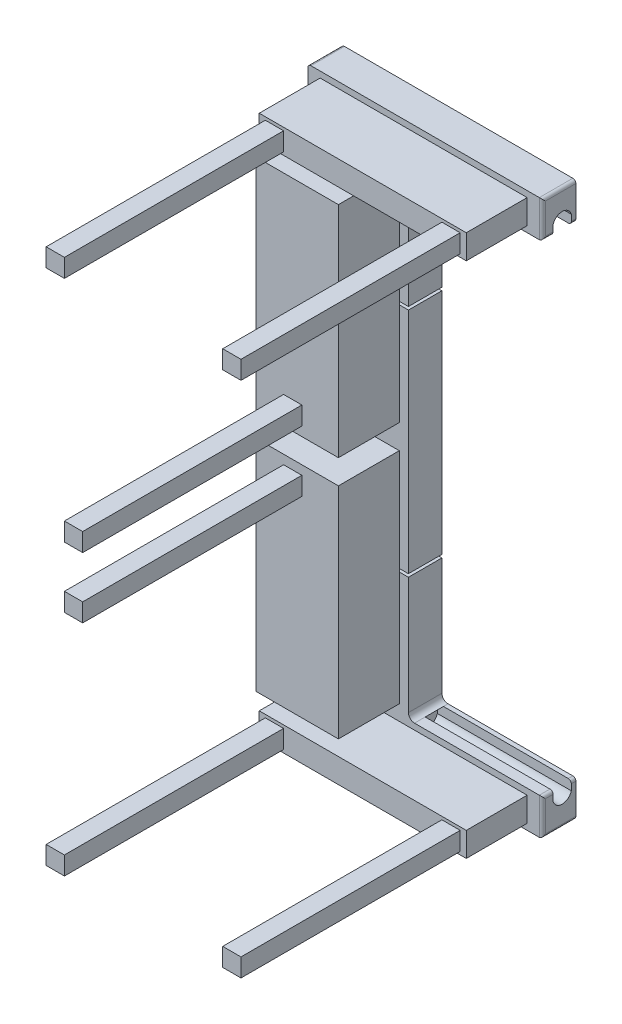
from build123d import *

# Parameters (mm, degrees)
BOSS_EXTRUDE1_DEPTH = 241.3
FILLET1_R           = 25.4
FILLET2_R           = 12.7
CUT_EXTRUDE1_DEPTH  = 558.8
SKETCH3_W           = 1114.093901139
SKETCH3_H           = 2455.440787086
CUT_EXTRUDE5_DEPTH  = 101.6
SKETCH4_W           = 139.7
SKETCH4_H           = 12.7
CUT_EXTRUDE6_DEPTH  = 401.32
SKETCH9_W           = 863.6
SKETCH9_H           = 101.6
SKETCH9_W_2         = 342.9
SKETCH9_H_2         = 914.4
BOSS_EXTRUDE5_DEPTH = 254
SKETCH10_W          = 76.2
SKETCH10_H          = 76.2
BOSS_EXTRUDE6_DEPTH = 914.4


with BuildPart() as part:
    # Sketch1 → Boss-Extrude1 (new body)
    with BuildSketch(Plane.XY):
        Polygon((977.9, -152.4), (419.1, -152.4), (419.1, -2159), (977.9, -2159), (977.9, -2311.4), (0, -2311.4), (0, 0), (977.9, 0), align=None)
    extrude(amount=BOSS_EXTRUDE1_DEPTH)

    # Fillet1
    fillet1_edges = [part.edges().sort_by_distance(p)[0] for p in [
        (419.1, -152.4, 120.65),
        (419.1, -2159, 120.65),
    ]]
    fillet(fillet1_edges, radius=FILLET1_R)

    # Fillet2
    fillet2_edges = [part.edges().sort_by_distance(p)[0] for p in [
        (977.9, -2235.2, 241.3),
        (0, 0, 120.65),
        (977.9, 0, 120.65),
        (977.9, -152.4, 120.65),
        (977.9, -2159, 120.65),
        (977.9, -2311.4, 120.65),
        (0, -2311.4, 120.65),
        (977.9, -76.2, 241.3),
        (977.9, -76.2, 0),
        (977.9, -2235.2, 0),
    ]]
    fillet(fillet2_edges, radius=FILLET2_R)

    # Sketch2 → Cut-Extrude1 (cut)
    with BuildSketch(Plane(origin=(977.9, 0, 0), x_dir=(0, 0, -1), z_dir=(1, 0, 0))):
        with BuildLine():
            Line((-196.85, -152.4), (-196.85, -114.3))
            ThreePointArc((-196.85, -114.3), (-158.73, -85.205737384), (-120.61, -114.3))
            Line((-120.61, -114.3), (-120.61, -152.4))
            Line((-120.61, -152.4), (-196.85, -152.4))
        make_face()
    cut_extrude1 = extrude(amount=-CUT_EXTRUDE1_DEPTH, mode=Mode.SUBTRACT)

    # Mirror1: Cut-Extrude1 across plane
    add(cut_extrude1.mirror(Plane.ZX.offset(-1155.7)), mode=Mode.SUBTRACT)

    # Sketch3 → Cut-Extrude5 (cut)
    with BuildSketch(Plane(origin=(0, 0, 0), x_dir=(-1, 0, 0), z_dir=(0, 0, -1))):
        with Locations((-472.168855083, -1170.106383975)):
            Rectangle(SKETCH3_W, SKETCH3_H)
    extrude(amount=-CUT_EXTRUDE5_DEPTH, mode=Mode.SUBTRACT)

    # Sketch4 → Cut-Extrude6 (cut)
    with BuildSketch(Plane(origin=(419.1, 0, 0), x_dir=(0, 0, -1), z_dir=(1, 0, 0))):
        with Locations((-171.45, -673.1)):
            Rectangle(SKETCH4_W, SKETCH4_H)
    cut_extrude6 = extrude(amount=-CUT_EXTRUDE6_DEPTH, mode=Mode.SUBTRACT)

    # Mirror2: Cut-Extrude6 across plane
    add(cut_extrude6.mirror(Plane.ZX.offset(-1155.7)), mode=Mode.SUBTRACT)

    # Sketch9 → Boss-Extrude5 (add)
    with BuildSketch(Plane.XY.offset(241.3)):
        with Locations((482.6, -76.2)):
            Rectangle(SKETCH9_W, SKETCH9_H)
        with Locations((209.55, -647.7)):
            Rectangle(SKETCH9_W_2, SKETCH9_H_2)
    boss_extrude5 = extrude(amount=BOSS_EXTRUDE5_DEPTH)

    # Sketch10 → Boss-Extrude6 (add)
    with BuildSketch(Plane.XY.offset(495.3)):
        with Locations((114.3, -76.2)):
            Rectangle(SKETCH10_W, SKETCH10_H)
        with Locations((850.9, -76.2)):
            Rectangle(SKETCH10_W, SKETCH10_H)
        with Locations((190.5, -1028.7)):
            Rectangle(SKETCH10_W, SKETCH10_H)
    boss_extrude6 = extrude(amount=BOSS_EXTRUDE6_DEPTH)

    # Mirror4: Boss-Extrude5, Boss-Extrude6 across plane
    add(boss_extrude5.mirror(Plane.ZX.offset(-1155.7)))
    add(boss_extrude6.mirror(Plane.ZX.offset(-1155.7)))


solid = part.part
